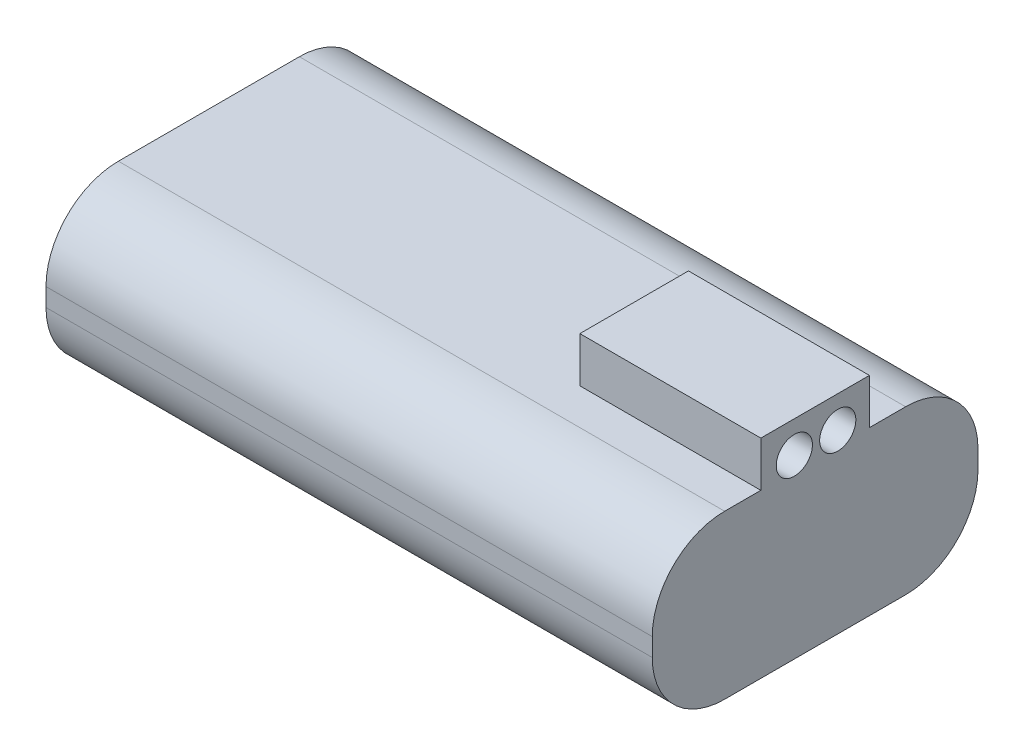
from build123d import *

# Parameters (mm, degrees)
SKETCH_1_W          = 67
SKETCH_1_H          = 36
EXTRUDE_1_DEPTH     = 18
SKETCH_2_W          = 20
SKETCH_2_H          = 12
EXTRUDE_2_DEPTH     = 5
FILLET_1_R          = 8
SKETCH_3_R          = 2
CUT_EXTRUDE_1_DEPTH = 5


with BuildPart() as part:
    # 草图1 → 凸台-拉伸1 (new body)
    with BuildSketch(Plane(origin=(0, 0, 0), x_dir=(1, 0, 0), z_dir=(0, 1, 0))):
        Rectangle(SKETCH_1_W, SKETCH_1_H)
    extrude(amount=EXTRUDE_1_DEPTH)

    # 草图2 → 凸台-拉伸2 (add)
    with BuildSketch(Plane(origin=(0, 18, 0), x_dir=(1, 0, 0), z_dir=(0, 1, 0))):
        with Locations((23.5, 0)):
            Rectangle(SKETCH_2_W, SKETCH_2_H)
    extrude(amount=EXTRUDE_2_DEPTH)

    # 圆角1
    fillet_1_edges = [part.edges().sort_by_distance(p)[0] for p in [
        (0, 18, 18),
        (0, 0, 18),
        (0, 0, -18),
        (0, 18, -18),
    ]]
    fillet(fillet_1_edges, radius=FILLET_1_R)

    # 草图3 → 切除-拉伸1 (cut)
    with BuildSketch(Plane(origin=(33.5, 0, 0), x_dir=(0, 0, -1), z_dir=(1, 0, 0))):
        with Locations((2.5, 19.5)):
            Circle(SKETCH_3_R)
        with Locations((-2.3, 19.5)):
            Circle(SKETCH_3_R)
    extrude(amount=-CUT_EXTRUDE_1_DEPTH, mode=Mode.SUBTRACT)


solid = part.part
